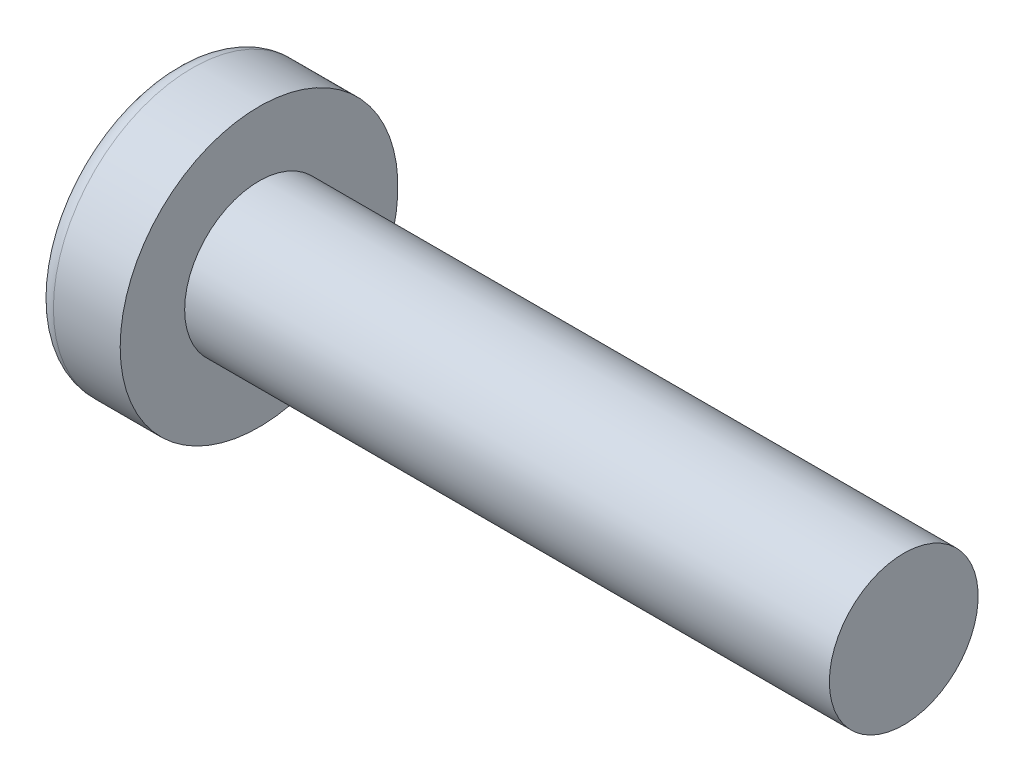
from build123d import *

# Parameters (mm, degrees)
SKETCH3_W         = 0.74
SKETCH3_H         = 2.9
SKETCH4_W         = 0.37
SKETCH4_H         = 0.37
CIRPATTERN1_COUNT = 2
CIRPATTERN1_ANGLE = 90


with BuildPart() as part:
    # BodySke → Base-Revolve (revolve)
    with BuildSketch(Plane.XY):
        with BuildLine():
            Line((2.4, 1.5), (2.4, 2.8))
            Line((2.4, 2.8), (1.053355856, 2.8))
            ThreePointArc((1.053355856, 2.8), (0.878072834, 2.754445324), (0.747150707, 2.629310345))
            ThreePointArc((0.747150707, 2.629310345), (0.190413403, 1.366702882), (0, 0))
            Line((0, 0), (15.4, 0))
            Line((15.4, 0), (15.4, 1.5))
            Line((15.4, 1.5), (2.4, 1.5))
        make_face()
    revolve(axis=Axis((-25.4, 0, 0), (1, 0, 0)))

    # Sketch3 → Cut-Loft1 section 0
    with BuildSketch(Plane(origin=(0, 0, 0), x_dir=(0, 0, -1), z_dir=(1, 0, 0))):
        Rectangle(SKETCH3_W, SKETCH3_H)
    # Sketch4 → Cut-Loft1 section 1
    with BuildSketch(Plane(origin=(1.76, 0, 0), x_dir=(0, 0, -1), z_dir=(1, 0, 0))):
        Rectangle(SKETCH4_W, SKETCH4_H)
    cut_loft1 = loft(mode=Mode.SUBTRACT)

    # CirPattern1: Cut-Loft1 ×2 about axis
    cirpattern1_axis = Axis((0, 0, 0), (1, 0, 0))
    for i in range(1, CIRPATTERN1_COUNT):
        add(cut_loft1.rotate(cirpattern1_axis, i * CIRPATTERN1_ANGLE / (CIRPATTERN1_COUNT - 1)), mode=Mode.SUBTRACT)


solid = part.part
